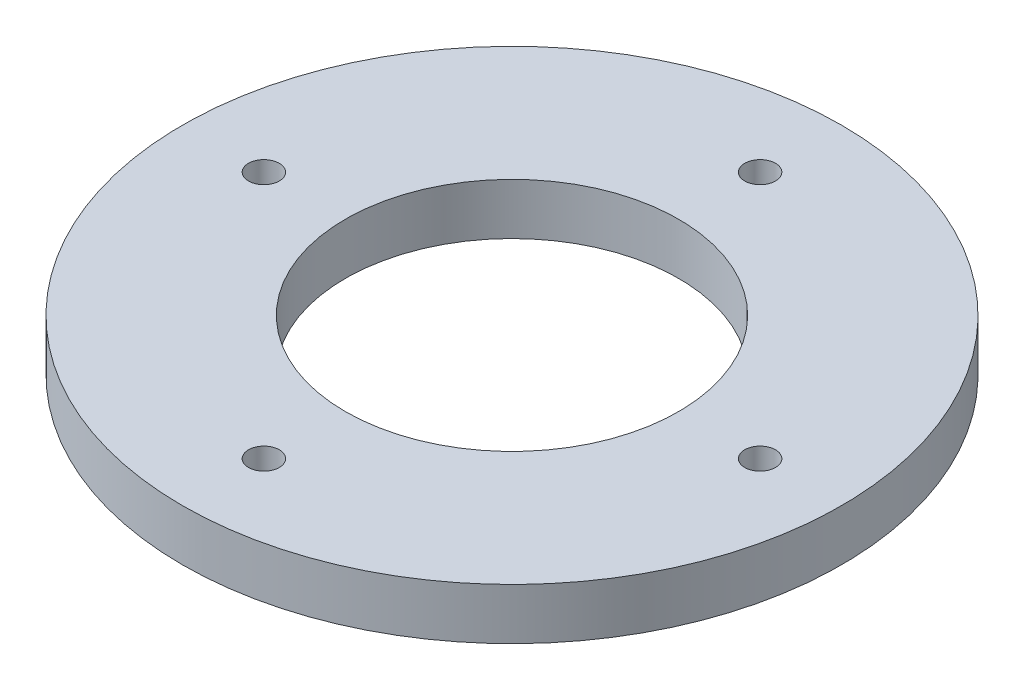
from build123d import *

# Parameters (mm, degrees)
SKETCH1_R           = 32.135
SKETCH1_R_2         = 16.25
BOSS_EXTRUDE1_DEPTH = 2.5
SKETCH2_R           = 1.5
CUT_EXTRUDE1_DEPTH  = 6
CIRPATTERN1_COUNT   = 4


with BuildPart() as part:
    # Sketch1 → Boss-Extrude1 (new body, symmetric)
    with BuildSketch(Plane(origin=(0, 0, 0), x_dir=(1, 0, 0), z_dir=(0, 1, 0))):
        Circle(SKETCH1_R)
        Circle(SKETCH1_R_2, mode=Mode.SUBTRACT)
    extrude(amount=BOSS_EXTRUDE1_DEPTH, both=True)

    # Sketch2 → Cut-Extrude1 (cut, through all)
    with BuildSketch(Plane(origin=(0, 2.5, 0), x_dir=(1, 0, 0), z_dir=(0, 1, 0))):
        with Locations((0, 24.1925)):
            Circle(SKETCH2_R)
    cut_extrude1 = extrude(amount=-CUT_EXTRUDE1_DEPTH, mode=Mode.SUBTRACT)

    # CirPattern1: Cut-Extrude1 ×4 about axis
    cirpattern1_axis = Axis((0, 0, 0), (0, 1, 0))
    for i in range(1, CIRPATTERN1_COUNT):
        add(cut_extrude1.rotate(cirpattern1_axis, i * 360 / CIRPATTERN1_COUNT), mode=Mode.SUBTRACT)


solid = part.part
